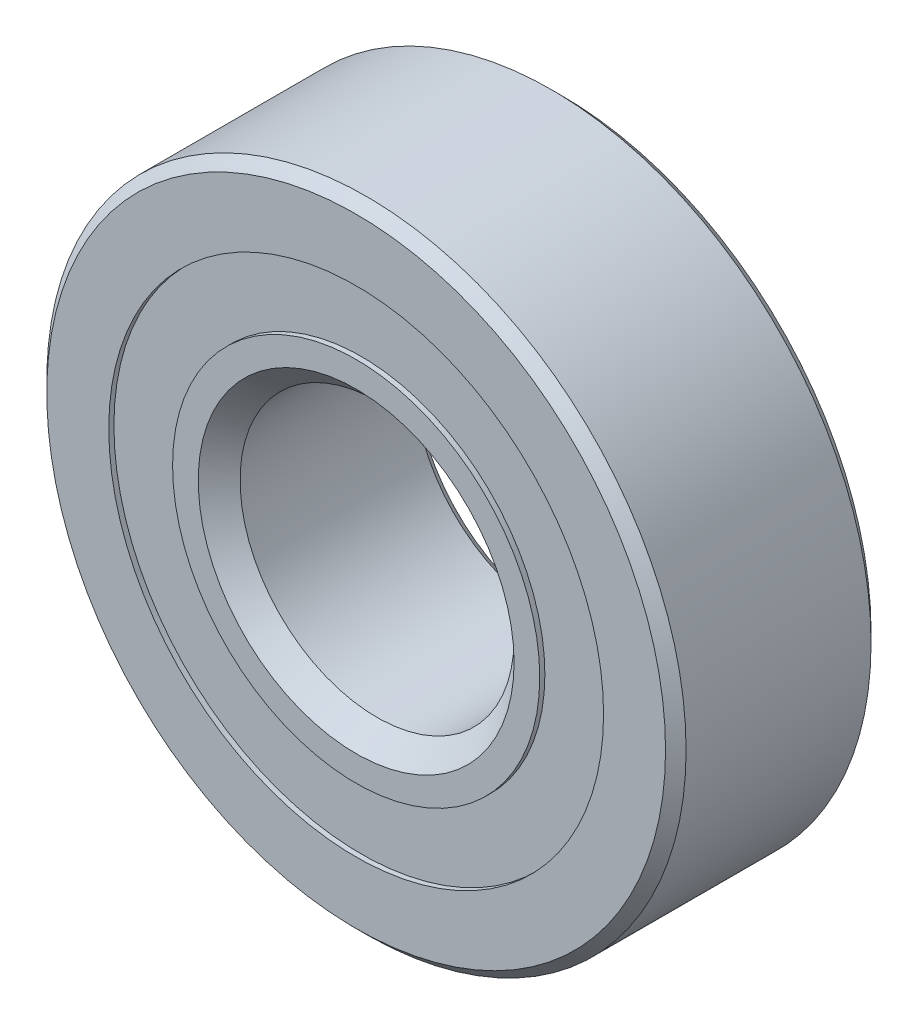
from build123d import *

# Parameters (mm, degrees)
CIRPATTERN1_COUNT = 12
SKETCH5_W         = 1.672929924
SKETCH5_H         = 2.218205964


with BuildPart() as part:
    # Sketch1 → Revolve1 (revolve)
    with BuildSketch(Plane(origin=(0, 0, 0), x_dir=(0, 0, -1), z_dir=(1, 0, 0))):
        with BuildLine():
            Line((3.2146875, 11.1125), (-3.2146875, 11.1125))
            Line((-3.2146875, 11.1125), (-3.571875, 10.7553125))
            Line((-3.571875, 10.7553125), (-3.571875, 8.600412088))
            Line((-3.571875, 8.600412088), (-1.5875, 8.600412088))
            ThreePointArc((-1.5875, 8.600412088), (0, 9.657851326), (1.5875, 8.600412088))
            Line((1.5875, 8.600412088), (3.571875, 8.600412088))
            Line((3.571875, 8.600412088), (3.571875, 10.7553125))
            Line((3.571875, 10.7553125), (3.2146875, 11.1125))
        make_face()
    revolve(axis=Axis((0, 0, 3.571875), (0, 0, -1)))


with BuildPart() as body_2:
    # Sketch3 → Revolve3 (revolve)
    with BuildSketch(Plane(origin=(0, 0, 0), x_dir=(0, 0, -1), z_dir=(1, 0, 0))):
        with BuildLine():
            Line((-3.39328125, 6.203612374), (-2.679493212, 5.489824337))
            Line((-2.679493212, 5.489824337), (0, 5.489824337))
            Line((0, 5.489824337), (0, 6.217148674))
            ThreePointArc((0, 6.217148674), (0.95372087, 6.505709098), (1.5875, 7.274587912))
            Line((1.5875, 7.274587912), (3.571875, 7.274587912))
            Line((3.571875, 7.274587912), (3.571875, 5.1196875))
            Line((3.571875, 5.1196875), (3.2146875, 4.7625))
            Line((3.2146875, 4.7625), (-2.844550663, 4.7625))
            Line((-2.844550663, 4.7625), (-3.571875, 5.489824337))
            Line((-3.571875, 5.489824337), (-3.571875, 6.382206124))
            Line((-3.571875, 6.382206124), (-3.39328125, 6.382206124))
            Line((-3.39328125, 6.382206124), (-3.39328125, 6.203612374))
        make_face()
    revolve(axis=Axis((0, 0, 3.571875), (0, 0, -1)))


with BuildPart() as body_3:
    # Sketch4 → Revolve4 (revolve)
    with BuildSketch(Plane(origin=(0, 0, 0), x_dir=(0, 0, -1), z_dir=(1, 0, 0))):
        with BuildLine():
            Line((-1.720351326, 7.9375), (1.720351326, 7.9375))
            ThreePointArc((1.720351326, 7.9375), (0, 9.657851326), (-1.720351326, 7.9375))
        make_face()
    revolve(axis=Axis((0, 7.9375, 1.720351326), (0, 0, -1)))


with BuildPart() as cirpattern1_1:
    # CirPattern1: pattern copy
    add(body_3.part.rotate(Axis((0, 0, -3.571875), (0, 0, 1)), 1 * 360 / CIRPATTERN1_COUNT))


with BuildPart() as cirpattern1_2:
    # CirPattern1: pattern copy
    add(body_3.part.rotate(Axis((0, 0, -3.571875), (0, 0, 1)), 2 * 360 / CIRPATTERN1_COUNT))


with BuildPart() as cirpattern1_3:
    # CirPattern1: pattern copy
    add(body_3.part.rotate(Axis((0, 0, -3.571875), (0, 0, 1)), 3 * 360 / CIRPATTERN1_COUNT))


with BuildPart() as cirpattern1_4:
    # CirPattern1: pattern copy
    add(body_3.part.rotate(Axis((0, 0, -3.571875), (0, 0, 1)), 4 * 360 / CIRPATTERN1_COUNT))


with BuildPart() as cirpattern1_5:
    # CirPattern1: pattern copy
    add(body_3.part.rotate(Axis((0, 0, -3.571875), (0, 0, 1)), 5 * 360 / CIRPATTERN1_COUNT))


with BuildPart() as cirpattern1_6:
    # CirPattern1: pattern copy
    add(body_3.part.rotate(Axis((0, 0, -3.571875), (0, 0, 1)), 6 * 360 / CIRPATTERN1_COUNT))


with BuildPart() as cirpattern1_7:
    # CirPattern1: pattern copy
    add(body_3.part.rotate(Axis((0, 0, -3.571875), (0, 0, 1)), 7 * 360 / CIRPATTERN1_COUNT))


with BuildPart() as cirpattern1_8:
    # CirPattern1: pattern copy
    add(body_3.part.rotate(Axis((0, 0, -3.571875), (0, 0, 1)), 8 * 360 / CIRPATTERN1_COUNT))


with BuildPart() as cirpattern1_9:
    # CirPattern1: pattern copy
    add(body_3.part.rotate(Axis((0, 0, -3.571875), (0, 0, 1)), 9 * 360 / CIRPATTERN1_COUNT))


with BuildPart() as cirpattern1_10:
    # CirPattern1: pattern copy
    add(body_3.part.rotate(Axis((0, 0, -3.571875), (0, 0, 1)), 10 * 360 / CIRPATTERN1_COUNT))


with BuildPart() as cirpattern1_11:
    # CirPattern1: pattern copy
    add(body_3.part.rotate(Axis((0, 0, -3.571875), (0, 0, 1)), 11 * 360 / CIRPATTERN1_COUNT))


with BuildPart() as body_15:
    # Sketch5 → Revolve5 (revolve)
    with BuildSketch(Plane(origin=(0, 0, 0), x_dir=(0, 0, -1), z_dir=(1, 0, 0))):
        with Locations((-2.556816288, 7.491309106)):
            Rectangle(SKETCH5_W, SKETCH5_H)
        with Locations((2.556816288, 7.491309106)):
            Rectangle(SKETCH5_W, SKETCH5_H)
    revolve(axis=Axis((0, 0, 3.571875), (0, 0, -1)))


solid = Compound([part.part, body_2.part, body_3.part, cirpattern1_1.part, cirpattern1_2.part, cirpattern1_3.part, cirpattern1_4.part, cirpattern1_5.part, cirpattern1_6.part, cirpattern1_7.part, cirpattern1_8.part, cirpattern1_9.part, cirpattern1_10.part, cirpattern1_11.part, body_15.part])
